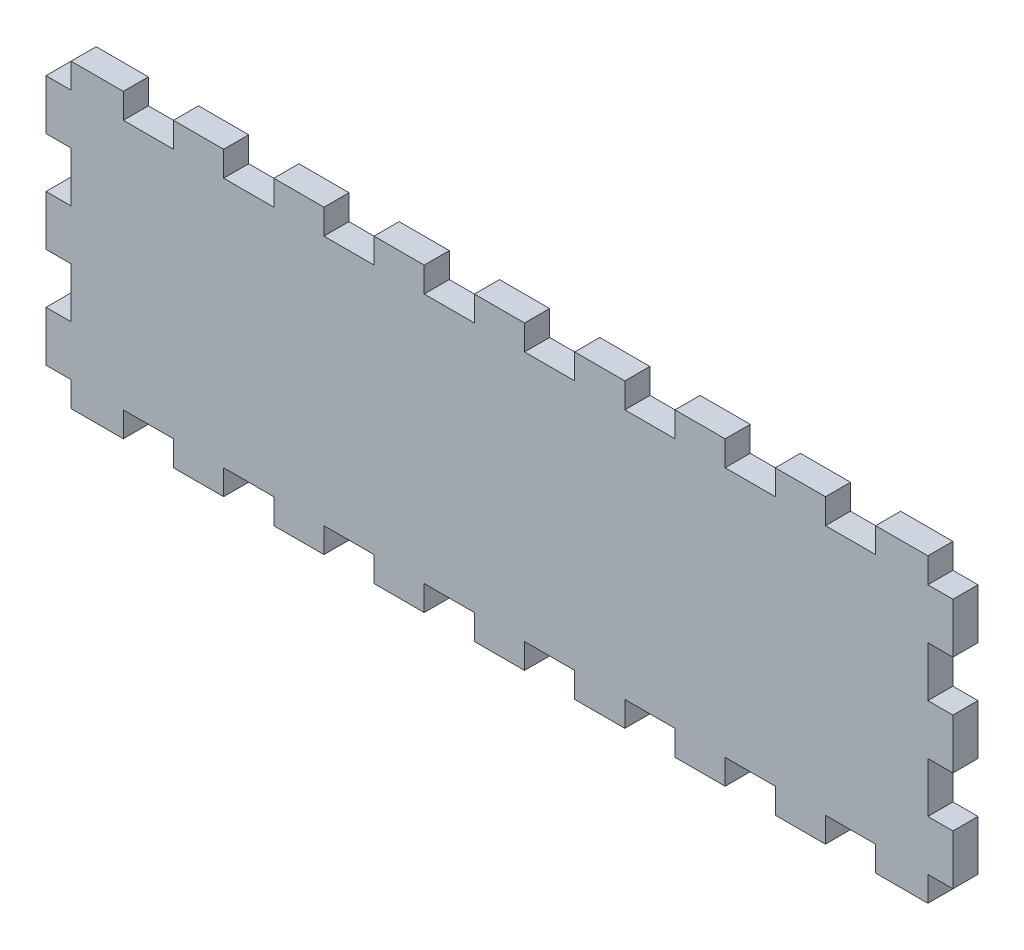
from build123d import *

# Parameters (mm, degrees)
BOSS_EXTRUDE1_DEPTH = 6
SKETCH3_W           = 6
SKETCH3_H           = 12
BOSS_EXTRUDE2_DEPTH = 6


with BuildPart() as part:
    # Sketch2 → Boss-Extrude1 (new body)
    with BuildSketch(Plane.XY):
        Polygon((-66, 6), (-78, 6), (-78, 0), (-90, 0), (-90, 6), (-102.5, 6), (-102.5, -65.99938194), (-90, -65.99938194), (-90, -59.99938194), (-78, -59.99938194), (-78, -65.99938194), (-66, -65.99938194), (-66, -59.99938194), (-54, -59.99938194), (-54, -65.99938194), (-42, -65.99938194), (-42, -59.99938194), (-30, -59.99938194), (-30, -65.99938194), (-18, -65.99938194), (-18, -59.99938194), (-6, -59.99938194), (-6, -65.99938194), (6, -65.99938194), (6, -59.99938194), (18, -59.99938194), (18, -65.99938194), (30, -65.99938194), (30, -59.99938194), (42, -59.99938194), (42, -65.99938194), (54, -65.99938194), (54, -59.99938194), (66, -59.99938194), (66, -65.99938194), (78, -65.99938194), (78, -59.99938194), (90, -59.99938194), (90, -65.99938194), (102.5, -65.99938194), (102.5, 6), (90, 6), (90, 0), (78, 0), (78, 6), (66, 6), (66, 0), (54, 0), (54, 6), (42, 6), (42, 0), (30, 0), (30, 6), (18, 6), (18, 0), (6, 0), (6, 6), (-6, 6), (-6, 0), (-18, 0), (-18, 6), (-30, 6), (-30, 0), (-42, 0), (-42, 6), (-54, 6), (-54, 0), (-66, 0), align=None)
    extrude(amount=BOSS_EXTRUDE1_DEPTH)

    # Sketch3 → Boss-Extrude2 (add)
    with BuildSketch(Plane.XY.offset(6)):
        with Locations((-105.5, -6)):
            Rectangle(SKETCH3_W, SKETCH3_H)
        with Locations((105.5, -6)):
            Rectangle(SKETCH3_W, SKETCH3_H)
        with Locations((105.5, -30)):
            Rectangle(SKETCH3_W, SKETCH3_H)
        with Locations((105.5, -54)):
            Rectangle(SKETCH3_W, SKETCH3_H)
        with Locations((-105.5, -30)):
            Rectangle(SKETCH3_W, SKETCH3_H)
        with Locations((-105.5, -54)):
            Rectangle(SKETCH3_W, SKETCH3_H)
    extrude(amount=-BOSS_EXTRUDE2_DEPTH)


solid = part.part
